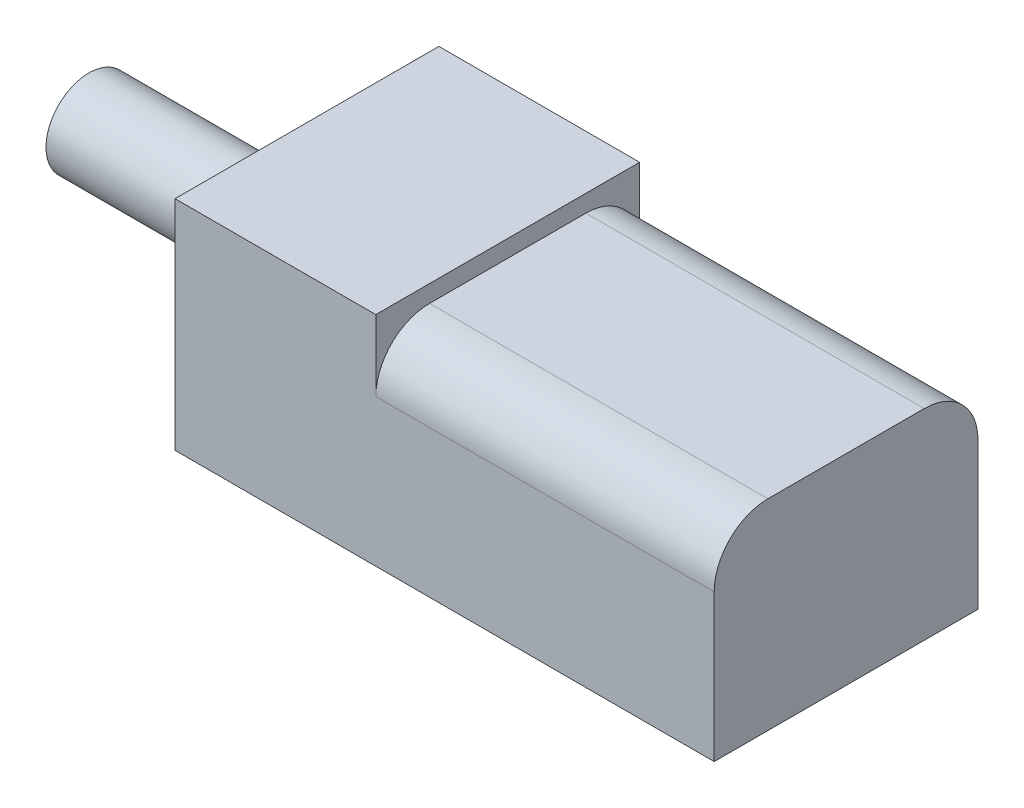
from build123d import *

# Parameters (mm, degrees)
SKETCH1_W           = 14.986
SKETCH1_H           = 11.684
BOSS_EXTRUDE2_DEPTH = 8.89
SKETCH3_W           = 8.89
SKETCH3_H           = 11.684
BOSS_EXTRUDE4_DEPTH = 9.652
FILLET1_R           = 2.38
SKETCH4_R           = 1.905
BOSS_EXTRUDE5_DEPTH = 9.652
SKETCH5_R           = 0.889
CUT_EXTRUDE1_DEPTH  = 7.112


with BuildPart() as part:
    # Sketch1 → Boss-Extrude2 (new body)
    with BuildSketch(Plane(origin=(0, 0, 0), x_dir=(1, 0, 0), z_dir=(0, 1, 0))):
        with Locations((7.493, 5.842)):
            Rectangle(SKETCH1_W, SKETCH1_H)
    extrude(amount=BOSS_EXTRUDE2_DEPTH)

    # Sketch3 → Boss-Extrude4 (add)
    with BuildSketch(Plane.XZ):
        with Locations((-4.445, -5.842)):
            Rectangle(SKETCH3_W, SKETCH3_H)
    extrude(amount=-BOSS_EXTRUDE4_DEPTH)

    # Fillet1
    fillet1_edges = [part.edges().sort_by_distance(p)[0] for p in [
        (7.493, 8.89, 0),
        (7.493, 8.89, -11.684),
    ]]
    fillet(fillet1_edges, radius=FILLET1_R)

    # Sketch4 → Boss-Extrude5 (add)
    with BuildSketch(Plane.ZY.offset(8.89)):
        with Locations((-5.842, 4.826)):
            Circle(SKETCH4_R)
    extrude(amount=BOSS_EXTRUDE5_DEPTH)

    # Sketch5 → Cut-Extrude1 (cut)
    with BuildSketch(Plane.ZY.offset(8.89)):
        with Locations((-1.397, 4.826)):
            Circle(SKETCH5_R)
        with Locations((-10.287, 4.826)):
            Circle(SKETCH5_R)
    extrude(amount=-CUT_EXTRUDE1_DEPTH, mode=Mode.SUBTRACT)


solid = part.part
